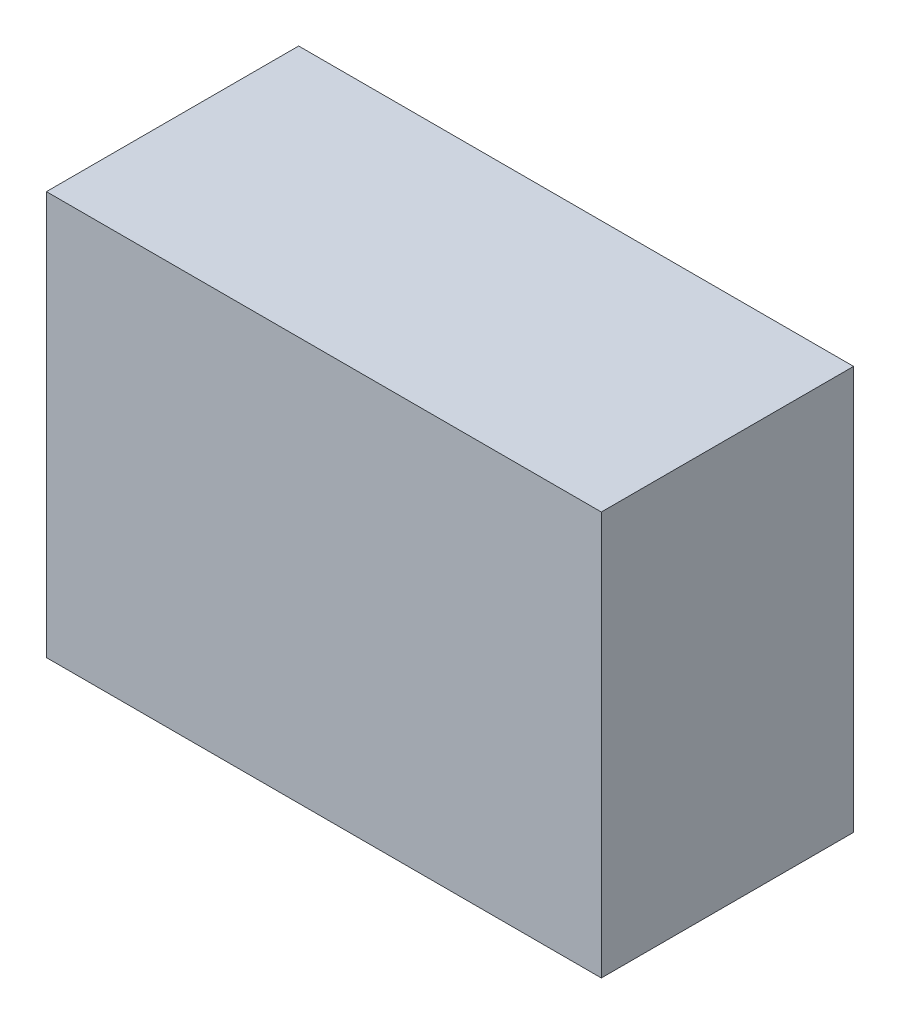
from build123d import *

# Parameters (mm, degrees)
SKETCH1_W           = 44
SKETCH1_H           = 32
BOSS_EXTRUDE1_DEPTH = 20


with BuildPart() as part:
    # Sketch1 → Boss-Extrude1 (new body)
    with BuildSketch(Plane.XY):
        with Locations((22, 16)):
            Rectangle(SKETCH1_W, SKETCH1_H)
    extrude(amount=BOSS_EXTRUDE1_DEPTH)


solid = part.part
